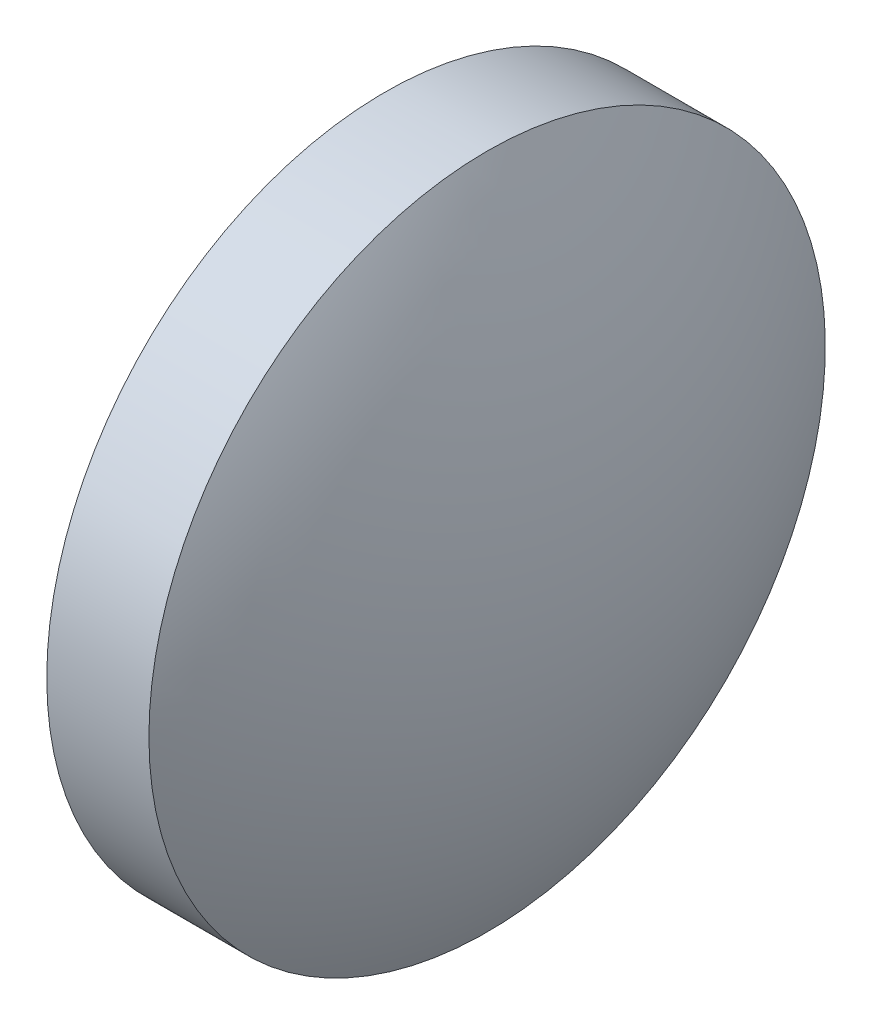
from build123d import *


with BuildPart() as part:
    # 草图1 → 旋转1 (revolve)
    with BuildSketch(Plane.XY):
        with BuildLine():
            Line((580.50910527, 182.983404293), (580.50910527, 187.983404293))
            Line((580.50910527, 187.983404293), (582.01910527, 187.983404293))
            ThreePointArc((582.01910527, 187.983404293), (582.981410062, 185.565268929), (583.30910527, 182.983404293))
            Line((583.30910527, 182.983404293), (580.50910527, 182.983404293))
        make_face()
    revolve(axis=Axis((579.277584696, 182.983404293, 0), (1, 0, 0)))


solid = part.part
